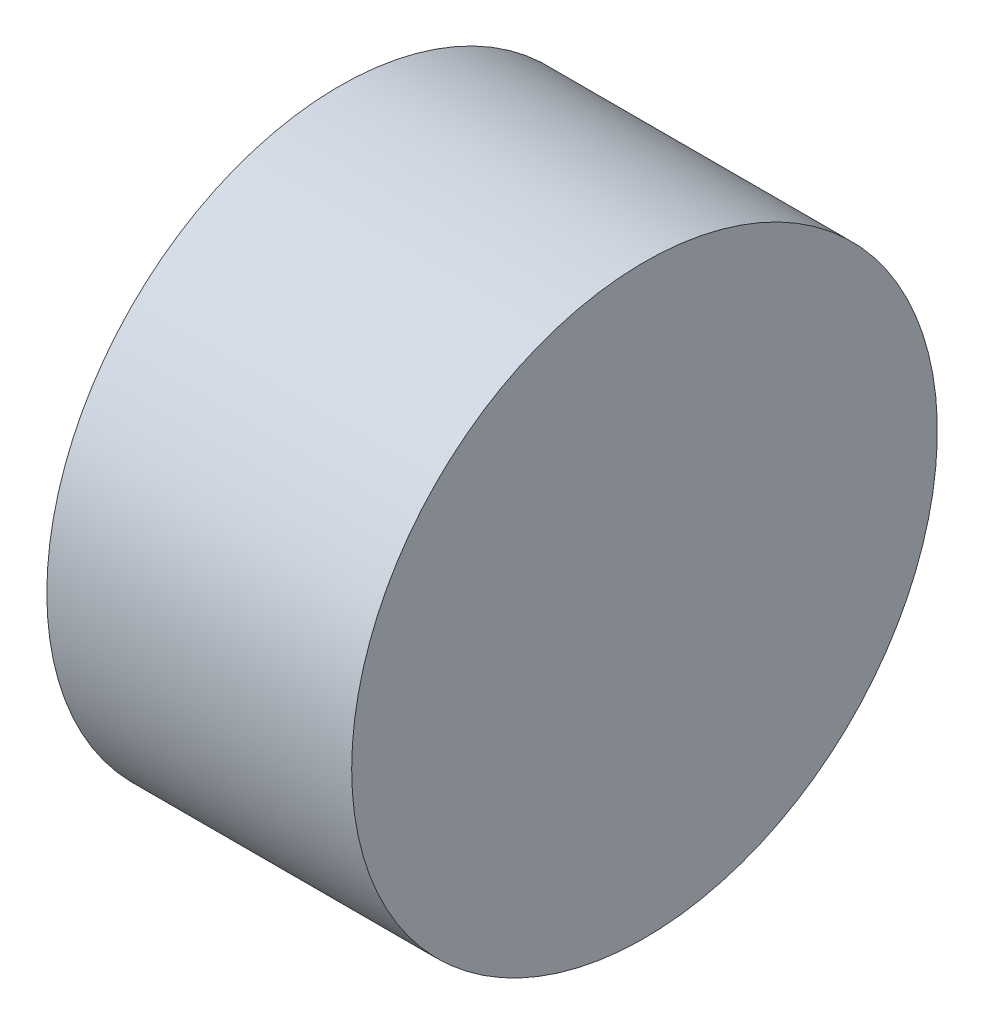
from build123d import *

# Parameters (mm, degrees)
CUT_EXTRUDE_1_DEPTH = 3
SKETCH_4_R          = 0.75
CUT_EXTRUDE_2_DEPTH = 3
SKETCH_6_R          = 0.65
CUT_EXTRUDE_3_DEPTH = 3


with BuildPart() as part:
    # 草图1 → 旋转1 (revolve)
    with BuildSketch(Plane(origin=(0, 0, 0), x_dir=(1, 0, 0), z_dir=(0, 1, 0))):
        Polygon((0, 0), (-16.7, 0), (-16.7, 3), (-12.7, 3), (-12.7, 12.2), (0, 12.2), align=None)
    revolve(axis=Axis((-159.613189405, 0, 0), (1, 0, 0)))

    # 草图3 → 切除-拉伸1 (cut)
    with BuildSketch(Plane.ZY.offset(12.7)):
        with BuildLine():
            ThreePointArc((-8.667998766, 2.421940832), (-8.99040601, 0.415451281), (-8.854419452, -1.612220883))
            ThreePointArc((-8.854419452, -1.612220883), (-9.764043418, -2.198869939), (-10.822068219, -1.97049219))
            ThreePointArc((-10.822068219, -1.97049219), (-10.988274013, 0.507773788), (-10.594220714, 2.960149905))
            ThreePointArc((-10.594220714, 2.960149905), (-9.519642991, 3.089978996), (-8.667998766, 2.421940832))
        make_face()
        with BuildLine():
            ThreePointArc((6.43146167, 6.295736716), (4.854994369, 7.578194355), (3.030985485, 8.474262622))
            ThreePointArc((3.030985485, 8.474262622), (2.977744482, 9.555344613), (3.704537815, 10.357432094))
            ThreePointArc((3.704537815, 10.357432094), (5.933882006, 9.262237545), (7.860675374, 7.694789319))
            ThreePointArc((7.860675374, 7.694789319), (7.435821803, 6.699263167), (6.43146167, 6.295736716))
        make_face()
        with BuildLine():
            ThreePointArc((2.236537096, -8.717677547), (4.135411642, -7.993645636), (5.823433967, -6.862041739))
            ThreePointArc((5.823433967, -6.862041739), (6.786298936, -7.356474674), (7.117530404, -8.386939904))
            ThreePointArc((7.117530404, -8.386939904), (5.054392007, -9.770011333), (2.73354534, -10.654939224))
            ThreePointArc((2.73354534, -10.654939224), (2.083821188, -9.789242163), (2.236537096, -8.717677547))
        make_face()
    extrude(amount=-CUT_EXTRUDE_1_DEPTH, mode=Mode.SUBTRACT)

    # 草图4 → 切除-拉伸2 (cut)
    with BuildSketch(Plane.ZY.offset(12.7)):
        with Locations((-2.818506641, 5.448101727)):
            Circle(SKETCH_4_R)
        with Locations((-4.135411642, 7.993645636)):
            Circle(SKETCH_4_R)
        with Locations((8.99040601, -0.415451281)):
            Circle(SKETCH_4_R)
        with Locations((6.127447818, -0.283152512)):
            Circle(SKETCH_4_R)
        with Locations((-4.854994369, -7.578194355)):
            Circle(SKETCH_4_R)
        with Locations((-3.308941178, -5.164949215)):
            Circle(SKETCH_4_R)
    extrude(amount=-CUT_EXTRUDE_2_DEPTH, mode=Mode.SUBTRACT)

    # 草图6 → 切除-拉伸3 (cut)
    with BuildSketch(Plane.ZY.offset(12.7)):
        with Locations((0, 5.083503848)):
            Circle(SKETCH_6_R)
        with Locations((0, -5.083503848)):
            Circle(SKETCH_6_R)
    extrude(amount=-CUT_EXTRUDE_3_DEPTH, mode=Mode.SUBTRACT)


solid = part.part
